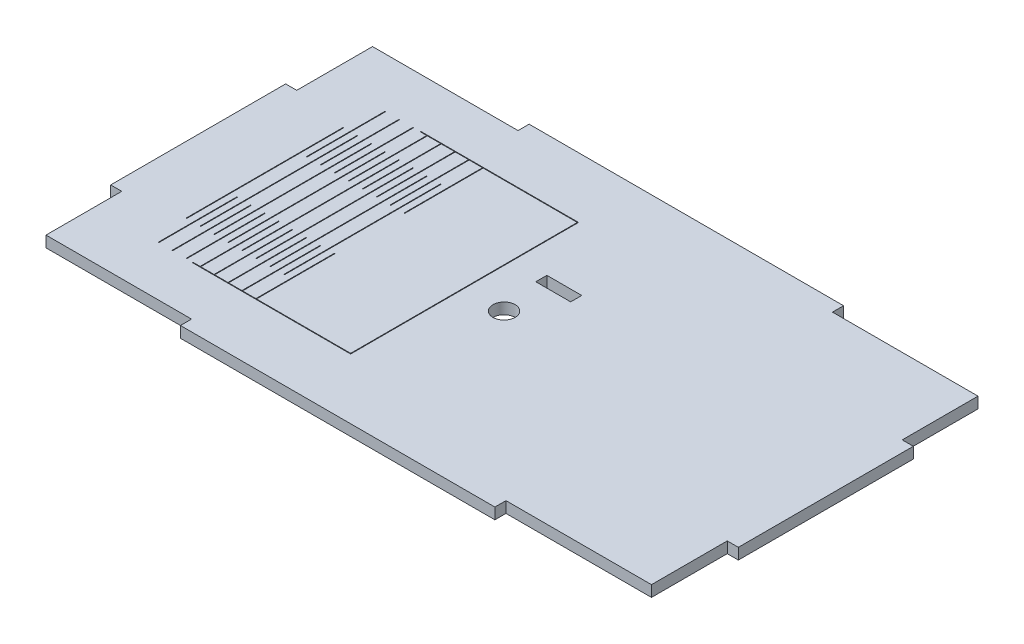
from build123d import *

# Parameters (mm, degrees)
SKETCH1_W                    = 180
SKETCH1_H                    = 100
BOSS_EXTRUDE1_DEPTH          = 3.18
SKETCH3_W                    = 44.91
SKETCH3_H                    = 3.18
CUT_EXTRUDE1_DEPTH           = 3.18
MIRROR2_COPY_1_SKETCH_W      = 44.91
MIRROR2_COPY_1_SKETCH_H      = 3.18
MIRROR2_COPY_1_DEPTH         = 3.18
SKETCH4_W                    = 3.18
SKETCH4_H                    = 24.91
CUT_EXTRUDE2_DEPTH           = 3.18
MIRROR4_COPY_1_SKETCH_W      = 3.18
MIRROR4_COPY_1_SKETCH_H      = 24.91
MIRROR4_COPY_1_DEPTH         = 3.18
SKETCH6_R                    = 3.18
CUT_EXTRUDE3_DEPTH           = 3.18
SKETCH7_W                    = 10
SKETCH7_H                    = 3.18
CUT_EXTRUDE4_DEPTH           = 3.18
SKETCH5_W                    = 0.18
SKETCH5_H                    = 45
SKETCH5_H_2                  = 22.5
CUT_EXTRUDE_THIN1_DEPTH      = 10
LPATTERN2_COUNT              = 5
LPATTERN2_PITCH              = 4
LPATTERN2_COL_COUNT          = 4
LPATTERN2_COL_PITCH          = 4
CUT_EXTRUDE_THIN2_DEPTH      = 1
CUT_EXTRUDE_THIN2_DEPTH_BACK = 10


with BuildPart() as part:
    # Sketch1 → Boss-Extrude1 (new body)
    with BuildSketch(Plane(origin=(0, 0, 0), x_dir=(1, 0, 0), z_dir=(0, 1, 0))):
        Rectangle(SKETCH1_W, SKETCH1_H)
    extrude(amount=BOSS_EXTRUDE1_DEPTH)

    # Sketch3 → Cut-Extrude1 (cut)
    with BuildSketch(Plane(origin=(0, 3.18, 0), x_dir=(1, 0, 0), z_dir=(0, 1, 0))):
        with Locations((67.545, -48.41)):
            Rectangle(SKETCH3_W, SKETCH3_H)
    cut_extrude1 = extrude(amount=-CUT_EXTRUDE1_DEPTH, mode=Mode.SUBTRACT)

    # Mirror1: Cut-Extrude1 across plane
    add(cut_extrude1.mirror(Plane(origin=(0, 0, 0), x_dir=(0, 0, 1), z_dir=(1, 0, 0))), mode=Mode.SUBTRACT)

    # Mirror2: Cut-Extrude1 across plane
    add(cut_extrude1.mirror(Plane.XY), mode=Mode.SUBTRACT)

    # Mirror2 copy 1 sketch → Mirror2 copy 1 (cut)
    with BuildSketch(Plane(origin=(0, 3.18, 0), x_dir=(-1, 0, 0), z_dir=(0, 1, 0))):
        with Locations((67.545, -48.41)):
            Rectangle(MIRROR2_COPY_1_SKETCH_W, MIRROR2_COPY_1_SKETCH_H)
    extrude(amount=-MIRROR2_COPY_1_DEPTH, mode=Mode.SUBTRACT)

    # Sketch4 → Cut-Extrude2 (cut)
    with BuildSketch(Plane(origin=(0, 3.18, 0), x_dir=(1, 0, 0), z_dir=(0, 1, 0))):
        with Locations((-88.41, 37.545)):
            Rectangle(SKETCH4_W, SKETCH4_H)
    cut_extrude2 = extrude(amount=-CUT_EXTRUDE2_DEPTH, mode=Mode.SUBTRACT)

    # Mirror3: Cut-Extrude2 across plane
    add(cut_extrude2.mirror(Plane.XY), mode=Mode.SUBTRACT)

    # Mirror4: Cut-Extrude2 across plane
    add(cut_extrude2.mirror(Plane(origin=(0, 0, 0), x_dir=(0, 0, 1), z_dir=(1, 0, 0))), mode=Mode.SUBTRACT)

    # Mirror4 copy 1 sketch → Mirror4 copy 1 (cut)
    with BuildSketch(Plane(origin=(0, 3.18, 0), x_dir=(-1, 0, 0), z_dir=(0, 1, 0))):
        with Locations((-88.41, 37.545)):
            Rectangle(MIRROR4_COPY_1_SKETCH_W, MIRROR4_COPY_1_SKETCH_H)
    extrude(amount=-MIRROR4_COPY_1_DEPTH, mode=Mode.SUBTRACT)

    # Sketch6 → Cut-Extrude3 (cut)
    with BuildSketch(Plane(origin=(0, 3.18, 0), x_dir=(1, 0, 0), z_dir=(0, 1, 0))):
        with Locations((-2.271207142, 0)):
            Circle(SKETCH6_R)
    extrude(amount=-CUT_EXTRUDE3_DEPTH, mode=Mode.SUBTRACT)

    # Sketch7 → Cut-Extrude4 (cut)
    with BuildSketch(Plane(origin=(0, 3.18, 0), x_dir=(1, 0, 0), z_dir=(0, 1, 0))):
        with Locations((0, 13.41)):
            Rectangle(SKETCH7_W, SKETCH7_H)
    extrude(amount=-CUT_EXTRUDE4_DEPTH, mode=Mode.SUBTRACT)

    # Sketch5 → Cut-Extrude-Thin1 (cut)
    with BuildSketch(Plane(origin=(0, 3.18, 0), x_dir=(1, 0, 0), z_dir=(0, 1, 0))):
        with Locations((-58.861207142, 0)):
            Rectangle(SKETCH5_W, SKETCH5_H)
        with Locations((-56.861207142, 21.25)):
            Rectangle(SKETCH5_W, SKETCH5_H_2)
        with Locations((-56.861207142, -21.25)):
            Rectangle(SKETCH5_W, SKETCH5_H_2)
    cut_extrude_thin1 = extrude(amount=-CUT_EXTRUDE_THIN1_DEPTH, mode=Mode.SUBTRACT)

    # LPattern2: Cut-Extrude-Thin1 ×5
    with Locations(*[(i * LPATTERN2_PITCH, 0, 0) for i in range(1, LPATTERN2_COUNT)]):
        add(cut_extrude_thin1, mode=Mode.SUBTRACT)

    # LPattern2 col: Cut-Extrude-Thin1 ×4
    with Locations(*[(-i * LPATTERN2_COL_PITCH, 0, 0) for i in range(1, LPATTERN2_COL_COUNT)]):
        add(cut_extrude_thin1, mode=Mode.SUBTRACT)

    # Sketch9 → Cut-Extrude-Thin2 (cut, two sides)
    with BuildSketch(Plane(origin=(0, 3.18, 0), x_dir=(1, 0, 0), z_dir=(0, 1, 0))) as cut_extrude_thin2_sk:
        Polygon((-58.771207142, 32.5), (-13.771207142, 32.5), (-13.771207142, -32.5), (-58.951207142, -32.5), (-58.951207142, -32.68), (-13.591207142, -32.68), (-13.591207142, 32.68), (-58.771207142, 32.68), align=None)
    extrude(amount=CUT_EXTRUDE_THIN2_DEPTH, mode=Mode.SUBTRACT)
    extrude(cut_extrude_thin2_sk.sketch, amount=-CUT_EXTRUDE_THIN2_DEPTH_BACK, mode=Mode.SUBTRACT)


solid = part.part
